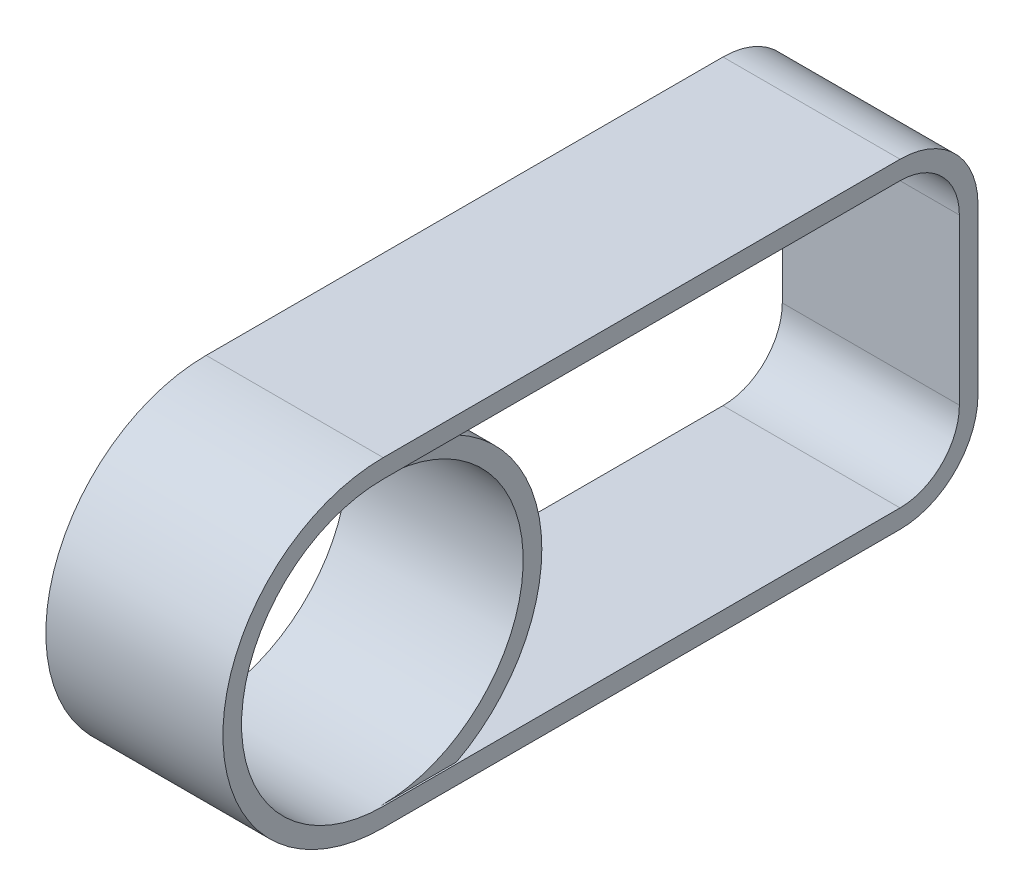
from build123d import *

# Parameters (mm, degrees)
SKETCH1_R           = 836
BOSS_EXTRUDE1_DEPTH = 1045
SKETCH2_W           = 1071.493924567
SKETCH2_H           = 1672
CUT_EXTRUDE1_DEPTH  = 10


with BuildPart() as part:
    # Sketch1 → Boss-Extrude1 (new body)
    with BuildSketch(Plane(origin=(0, 0, 0), x_dir=(0, 0, -1), z_dir=(1, 0, 0))):
        with BuildLine():
            Line((0, -110), (3050, -110))
            ThreePointArc((3050, -110), (3375.269119346, 24.730880654), (3510, 350))
            Line((3510, 350), (3510, 1322))
            ThreePointArc((3510, 1322), (3375.269119346, 1647.269119346), (3050, 1782))
            Line((3050, 1782), (0, 1782))
            ThreePointArc((0, 1782), (-946, 836), (0, -110))
        make_face()
        with Locations((0, 836)):
            Circle(SKETCH1_R, mode=Mode.SUBTRACT)
        with BuildLine():
            Line((442.741459545, 0), (3050, 0))
            ThreePointArc((3050, 0), (3297.487373415, 102.512626585), (3400, 350))
            Line((3400, 350), (3400, 1322))
            ThreePointArc((3400, 1322), (3297.487373415, 1569.487373415), (3050, 1672))
            Line((3050, 1672), (442.741459545, 1672))
            ThreePointArc((442.741459545, 1672), (946, 836), (442.741459545, 0))
        make_face(mode=Mode.SUBTRACT)
    extrude(amount=BOSS_EXTRUDE1_DEPTH)

    # Sketch2 → Cut-Extrude1 (cut)
    with BuildSketch(Plane(origin=(1045, 0, 0), x_dir=(0, 0, -1), z_dir=(1, 0, 0))):
        with Locations((535.746962284, 836)):
            Rectangle(SKETCH2_W, SKETCH2_H)
    extrude(amount=-CUT_EXTRUDE1_DEPTH, mode=Mode.SUBTRACT)


solid = part.part
